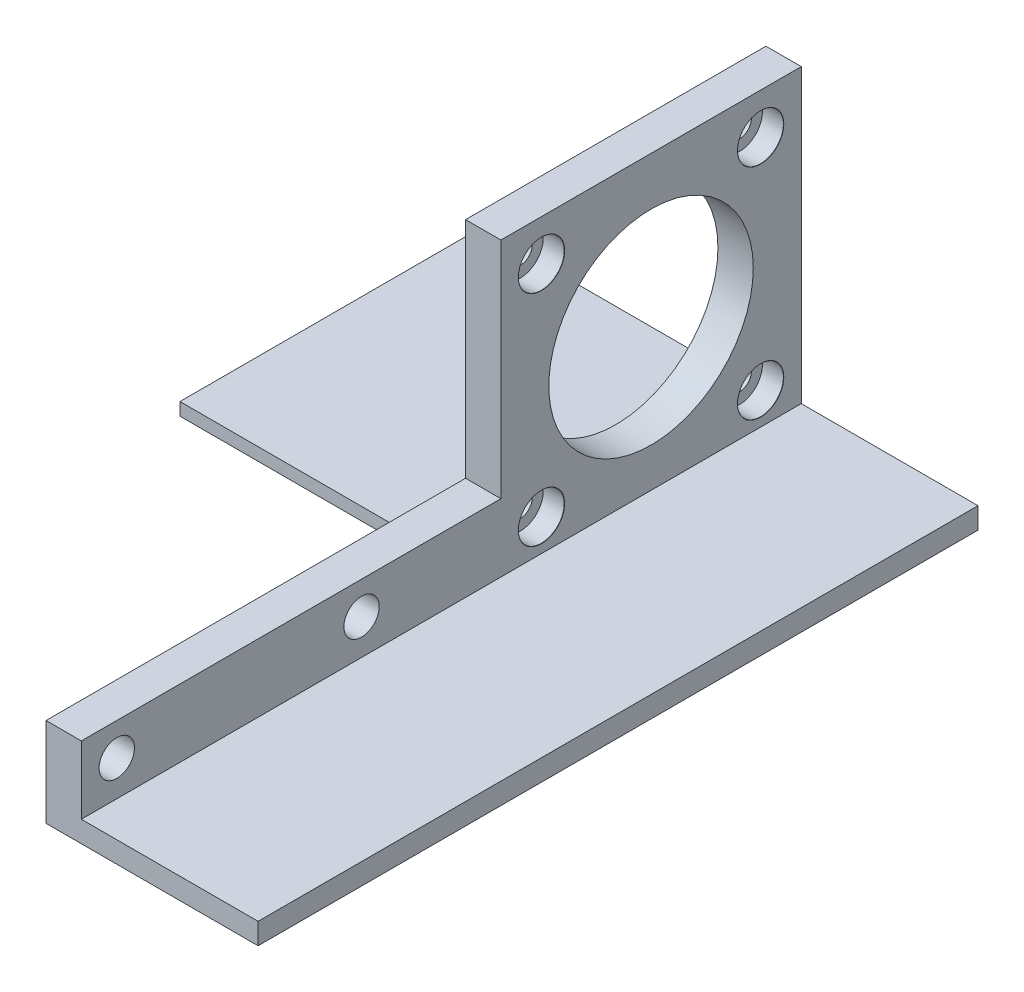
from build123d import *

# Parameters (mm, degrees)
SKETCH1_W                     = 101.835629046
SKETCH1_H                     = 3
BOSS_EXTRUDE1_DEPTH           = 12.5
SKETCH2_W                     = 42.486551299
SKETCH2_H                     = 1.8
BOSS_EXTRUDE2_DEPTH           = 45.4
SKETCH3_W                     = 42.486551299
SKETCH3_H                     = 42.486551299
BOSS_EXTRUDE3_DEPTH           = 5
CBORE_FOR_M3_SHCS2_AT_2_COUNT = 2
CBORE_FOR_M3_SHCS2_AT_2_PITCH = 31
CBORE_FOR_M3_SHCS2_AT_3_COUNT = 2
CBORE_FOR_M3_SHCS2_AT_3_PITCH = 43.840620434
CBORE_FOR_M3_SHCS2_AT_4_COUNT = 2
CBORE_FOR_M3_SHCS2_AT_4_PITCH = 31
SKETCH9_R                     = 14.462
CUT_EXTRUDE1_DEPTH            = 10
SKETCH10_W                    = 59.349077747
SKETCH10_H                    = 12.6
BOSS_EXTRUDE4_DEPTH           = 5
SKETCH11_R                    = 2.5
CUT_EXTRUDE2_DEPTH            = 10


with BuildPart() as part:
    # Sketch1 → Boss-Extrude1 (new, symmetric)
    with BuildSketch(Plane(origin=(0, 0, 0), x_dir=(0, 0, -1), z_dir=(1, 0, 0))):
        with Locations((5.332185477, -1.5)):
            Rectangle(SKETCH1_W, SKETCH1_H)
    extrude(amount=BOSS_EXTRUDE1_DEPTH, both=True)

    # Sketch2 → Boss-Extrude2 (add)
    with BuildSketch(Plane.ZY.offset(12.5)):
        with Locations((-35.006724351, -2.1)):
            Rectangle(SKETCH2_W, SKETCH2_H)
    extrude(amount=BOSS_EXTRUDE2_DEPTH)

    # Sketch3 → Boss-Extrude3 (add)
    with BuildSketch(Plane.ZY.offset(12.5)):
        with Locations((-35.006724351, 20.043275649)):
            Rectangle(SKETCH3_W, SKETCH3_H)
    extrude(amount=BOSS_EXTRUDE3_DEPTH)

    # Sketch8 → CBORE for M3 SHCS2 (revolve, cut)
    with BuildSketch(Plane(origin=(-12.5, 4.5, -19.5), x_dir=(0, 0, -1), z_dir=(0, 1, 0))):
        Polygon((0, 0), (0, 45.4), (1.7, 45.4), (1.7, 3), (3.25, 3), (3.25, 0.025), (3.275, 0), align=None)
    cbore_for_m3_shcs2 = revolve(axis=Axis((-6.15, 4.5, -19.5), (-1, 0, 0)), mode=Mode.SUBTRACT)

    # CBORE for M3 SHCS2 at 2: CBORE for M3 SHCS2 ×2
    with Locations(*[(0, 0, -i * CBORE_FOR_M3_SHCS2_AT_2_PITCH) for i in range(1, CBORE_FOR_M3_SHCS2_AT_2_COUNT)]):
        add(cbore_for_m3_shcs2, mode=Mode.SUBTRACT)

    # CBORE for M3 SHCS2 at 3: CBORE for M3 SHCS2 ×2
    with Locations(*[Vector(0, 0.7071067811865476, -0.7071067811865475) * (i * CBORE_FOR_M3_SHCS2_AT_3_PITCH) for i in range(1, CBORE_FOR_M3_SHCS2_AT_3_COUNT)]):
        add(cbore_for_m3_shcs2, mode=Mode.SUBTRACT)

    # CBORE for M3 SHCS2 at 4: CBORE for M3 SHCS2 ×2
    with Locations(*[(0, i * CBORE_FOR_M3_SHCS2_AT_4_PITCH, 0) for i in range(1, CBORE_FOR_M3_SHCS2_AT_4_COUNT)]):
        add(cbore_for_m3_shcs2, mode=Mode.SUBTRACT)

    # Sketch9 → Cut-Extrude1 (cut)
    with BuildSketch(Plane(origin=(-12.5, 0, 0), x_dir=(0, 0, -1), z_dir=(1, 0, 0))):
        with Locations((35, 20)):
            Circle(SKETCH9_R)
    extrude(amount=-CUT_EXTRUDE1_DEPTH, mode=Mode.SUBTRACT)

    # Sketch10 → Boss-Extrude4 (add)
    with BuildSketch(Plane.ZY.offset(12.5)):
        with Locations((15.911090172, 3.3)):
            Rectangle(SKETCH10_W, SKETCH10_H)
    extrude(amount=BOSS_EXTRUDE4_DEPTH)

    # Sketch11 → Cut-Extrude2 (cut)
    with BuildSketch(Plane.ZY.offset(17.5)):
        with Locations((5.95, 5)):
            Circle(SKETCH11_R)
        with Locations((40.574170501, 5)):
            Circle(SKETCH11_R)
    extrude(amount=-CUT_EXTRUDE2_DEPTH, mode=Mode.SUBTRACT)


solid = part.part
